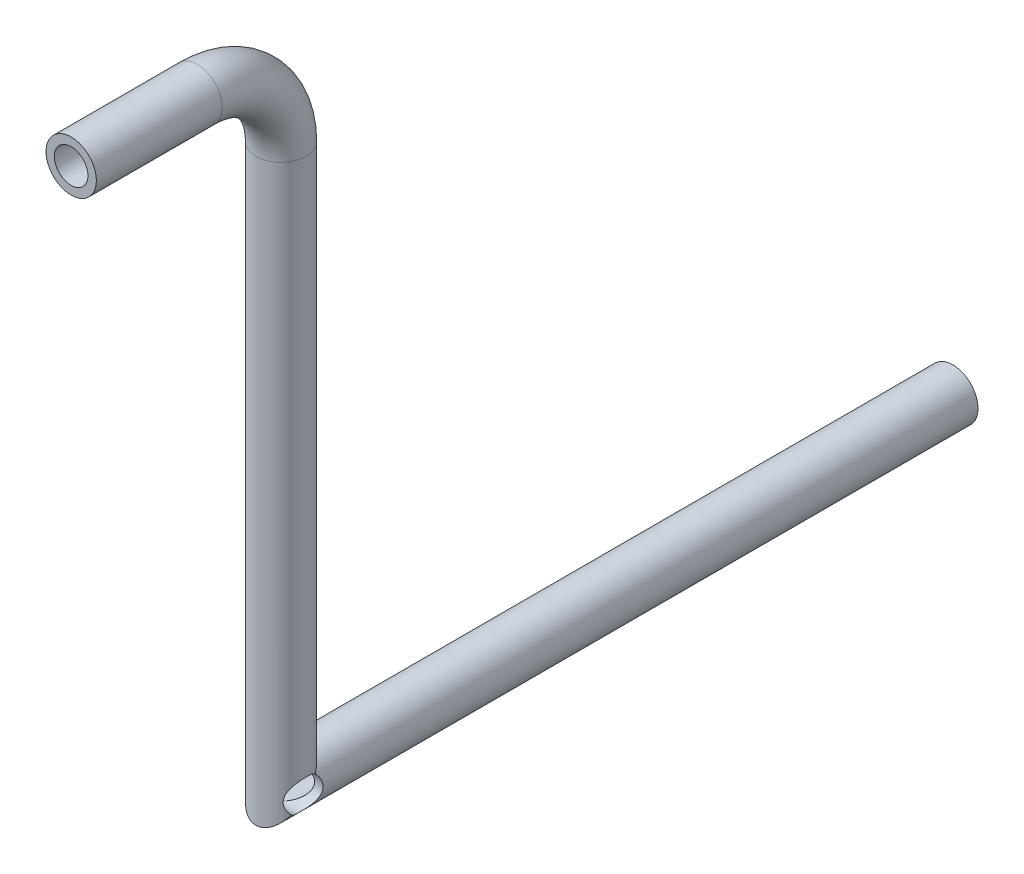
from build123d import *

# Parameters (mm, degrees)
SWEEP_THIN1_PROFILE_R   = 30
SWEEP_THIN1_PROFILE_R_2 = 20
CUT_EXTRUDE1_DEPTH      = 1227.693525611
CUT_EXTRUDE1_DEPTH_BACK = 1227.693525611
SKETCH3_R               = 20
SKETCH5_R               = 20
CUT_EXTRUDE3_DEPTH      = 111


with BuildPart() as part:
    # Sweep-Thin1: sweep along a path in Sketch1
    with BuildLine(Plane(origin=(0, 0, 0), x_dir=(0, 0, -1), z_dir=(1, 0, 0))) as sweep_thin1_path:
        Line((-41.871921182, 668.251231527), (108.128078818, 668.251231527))
        ThreePointArc((108.128078818, 668.251231527), (178.838756936, 638.961909646), (208.128078818, 568.251231527))
        Line((208.128078818, 568.251231527), (208.128078818, -91.748768473))
        Line((208.128078818, -91.748768473), (1008.128078818, -91.748768473))
    # Sweep-Thin1 profile (on start of the path) → Sweep-Thin1 (sweep)
    with BuildSketch(Plane(origin=(0, 668.251231527, 41.871921182), x_dir=(-1, 0, 0), z_dir=(0, 0, -1))):
        Circle(SWEEP_THIN1_PROFILE_R)
        Circle(SWEEP_THIN1_PROFILE_R_2, mode=Mode.SUBTRACT)
    sweep(path=sweep_thin1_path.line, transition=Transition.RIGHT)

    # Sketch3 → Cut-Extrude1 (cut, two sides: drawn at the far end of the back side and taken through both)
    with BuildSketch(Plane(origin=(0, 0, 0), x_dir=(0, 0, -1), z_dir=(1, 0, 0)).offset(-CUT_EXTRUDE1_DEPTH_BACK)):
        with Locations((208.128078818, -91.748768473)):
            Circle(SKETCH3_R)
    extrude(amount=CUT_EXTRUDE1_DEPTH + CUT_EXTRUDE1_DEPTH_BACK, mode=Mode.SUBTRACT)

    # Sketch5 → Cut-Extrude3 (cut)
    with BuildSketch(Plane.XY.offset(-330)):
        with Locations((0, 383.251231527)):
            Circle(SKETCH5_R)
    extrude(amount=CUT_EXTRUDE3_DEPTH, mode=Mode.SUBTRACT)


solid = part.part
